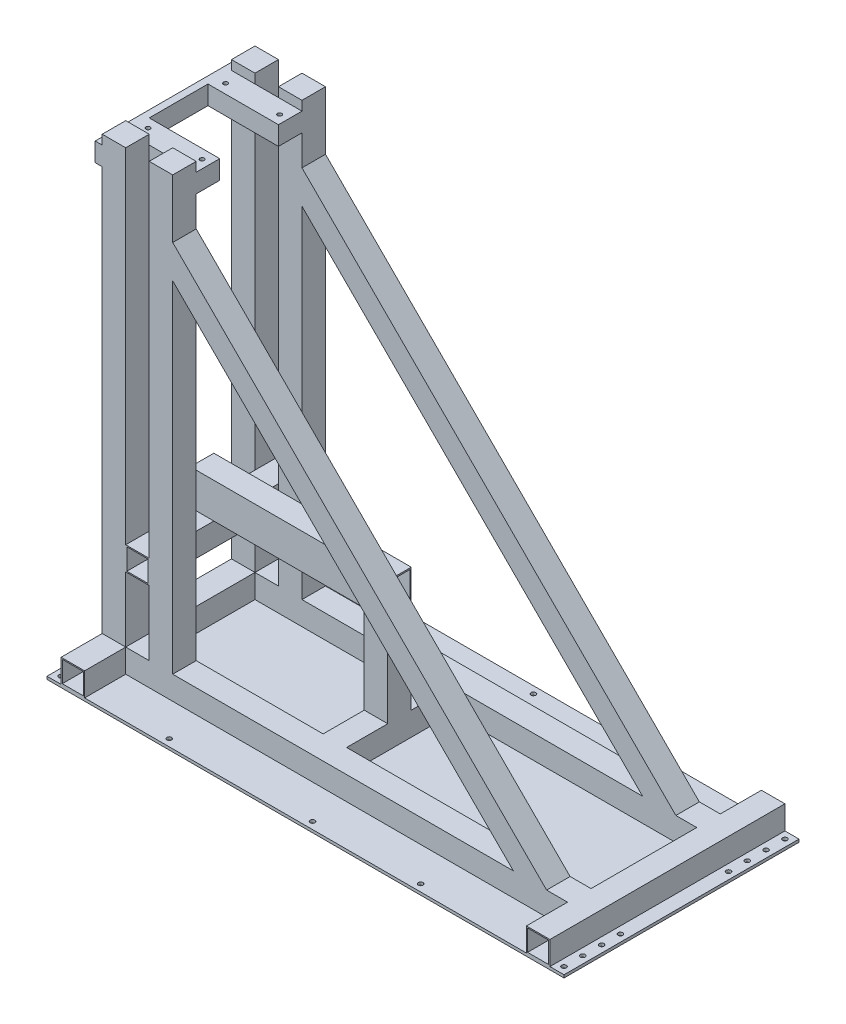
from build123d import *

# Parameters (mm, degrees)
BOSS_EXTRUDE1_DEPTH      = 100
CUT_EXTRUDE3_START       = 5
SKETCH15_W               = 95
SKETCH15_H               = 1837.5
SKETCH15_W_2             = 2080
SKETCH15_H_2             = 95
CUT_EXTRUDE3_DEPTH       = 90
BOSS_EXTRUDE2_DEPTH      = 100
SKETCH2_R                = 9
CUT_EXTRUDE1_DEPTH       = 41
CUT_EXTRUDE1_DEPTH_BACK  = 1901
SKETCH5_W                = 100
SKETCH5_H                = 100
SKETCH5_W_2              = 90
SKETCH5_H_2              = 90
BOSS_EXTRUDE6_DEPTH      = 500
BOSS_EXTRUDE6_DEPTH_BACK = 500
SKETCH6_W                = 650
SKETCH6_H                = 80
BOSS_EXTRUDE7_DEPTH      = 30
SKETCH7_W                = 650
SKETCH7_H                = 100
BOSS_EXTRUDE8_DEPTH      = 100
SKETCH8_W                = 90
SKETCH8_H                = 90
CUT_EXTRUDE2_DEPTH       = 380
SKETCH11_W               = 2200
SKETCH11_H               = 1000
SKETCH11_R               = 10
BOSS_EXTRUDE10_DEPTH     = 12
SKETCH12_W               = 100
SKETCH12_H               = 150
SKETCH12_W_2             = 88
SKETCH12_H_2             = 138
BOSS_EXTRUDE11_DEPTH     = 840
SKETCH18_W               = 100
SKETCH18_H               = 100
SKETCH18_W_2             = 90
SKETCH18_H_2             = 90
BOSS_EXTRUDE13_DEPTH     = 225
SKETCH14_W               = 100
SKETCH14_H               = 100
SKETCH14_W_2             = 90
SKETCH14_H_2             = 90
BOSS_EXTRUDE12_DEPTH     = 377
SKETCH16_W               = 90
SKETCH16_H               = 90
CUT_EXTRUDE4_DEPTH       = 826
SKETCH17_W               = 90
SKETCH17_H               = 90
CUT_EXTRUDE5_DEPTH       = 826


with BuildPart() as part:
    # Base → Boss-Extrude1 (new body)
    with BuildSketch(Plane.XY):
        Polygon((0, 100), (0, 1940), (100, 1940), (100, 1690.99025767), (1690.99025767, 100), (1880, 100), (1880, 0), (100, 0), (0, 0), (-100, 0), (-200, 0), (-200, 1940), (-100, 1940), (-100, 100), align=None)
        Polygon((100, 1549.568901432), (100, 100), (1549.568901432, 100), align=None, mode=Mode.SUBTRACT)
    extrude(amount=BOSS_EXTRUDE1_DEPTH)

    # Sketch15 → Cut-Extrude3 (cut)
    with BuildSketch(Plane.XY.offset(CUT_EXTRUDE3_START)):
        Polygon((100, 1687.454723764), (100, 1556.639969244), (1556.639969244, 100), (1687.454723764, 100), align=None)
        with Locations((-150, 1018.75)):
            Rectangle(SKETCH15_W, SKETCH15_H)
        with Locations((50, 1018.75)):
            Rectangle(SKETCH15_W, SKETCH15_H)
        with Locations((840, 50)):
            Rectangle(SKETCH15_W_2, SKETCH15_H_2)
    extrude(amount=CUT_EXTRUDE3_DEPTH, mode=Mode.SUBTRACT)

    # Sketch1 → Boss-Extrude2 (add)
    with BuildSketch(Plane(origin=(0, 0, 0), x_dir=(-1, 0, 0), z_dir=(0, 0, -1))):
        Polygon((-100, 1900), (10.419601085, 1900), (200, 1900), (200, 1820), (-100, 1820), align=None)
    extrude(amount=BOSS_EXTRUDE2_DEPTH)

    # Sketch2 → Cut-Extrude1 (cut, two sides)
    with BuildSketch(Plane(origin=(0, 1900, 0), x_dir=(1, 0, 0), z_dir=(0, 1, 0))) as cut_extrude1_sk:
        with Locations((-165, 60)):
            Circle(SKETCH2_R)
        with Locations((65, 60)):
            Circle(SKETCH2_R)
    extrude(amount=CUT_EXTRUDE1_DEPTH, mode=Mode.SUBTRACT)
    extrude(cut_extrude1_sk.sketch, amount=-CUT_EXTRUDE1_DEPTH_BACK, mode=Mode.SUBTRACT)


with BuildPart() as body_2:
    # Mirror2: mirrored copy
    add(part.part.mirror(Plane.XY.offset(-225)))


with BuildPart() as part_1:
    add(part.part)

    add(body_2.part)  # Boss-Extrude6 merges body 2
    # Sketch5 → Boss-Extrude6 (add, two sides)
    with BuildSketch(Plane.XY.offset(-225)) as boss_extrude6_sk:
        with Locations((-150, 50)):
            Rectangle(SKETCH5_W, SKETCH5_H)
        with Locations((-150, 50)):
            Rectangle(SKETCH5_W_2, SKETCH5_H_2, mode=Mode.SUBTRACT)
        with Locations((1830, 50)):
            Rectangle(SKETCH5_W, SKETCH5_H)
        with Locations((1830, 50)):
            Rectangle(SKETCH5_W_2, SKETCH5_H_2, mode=Mode.SUBTRACT)
    extrude(amount=BOSS_EXTRUDE6_DEPTH)
    extrude(boss_extrude6_sk.sketch, amount=-BOSS_EXTRUDE6_DEPTH_BACK)

    # Sketch6 → Boss-Extrude7 (add)
    with BuildSketch(Plane.ZY.offset(200)):
        with Locations((-225, 1860)):
            Rectangle(SKETCH6_W, SKETCH6_H)
    extrude(amount=BOSS_EXTRUDE7_DEPTH)

    # Sketch7 → Boss-Extrude8 (add)
    with BuildSketch(Plane.ZY):
        with Locations((-225, 427)):
            Rectangle(SKETCH7_W, SKETCH7_H)
    extrude(amount=BOSS_EXTRUDE8_DEPTH)

    # Sketch8 → Cut-Extrude2 (cut, symmetric)
    with BuildSketch(Plane.XY.offset(-225)):
        with Locations((-50, 427)):
            Rectangle(SKETCH8_W, SKETCH8_H)
    extrude(amount=CUT_EXTRUDE2_DEPTH, both=True, mode=Mode.SUBTRACT)

    # Sketch11 → Boss-Extrude10 (add)
    with BuildSketch(Plane(origin=(0, 0, 0), x_dir=(1, 0, 0), z_dir=(0, 1, 0))):
        with Locations((840, 225)):
            Rectangle(SKETCH11_W, SKETCH11_H)
        with Locations((-230, 695)):
            Circle(SKETCH11_R, mode=Mode.SUBTRACT)
        with Locations((1910, 695)):
            Circle(SKETCH11_R, mode=Mode.SUBTRACT)
        with Locations((1910, 455)):
            Circle(SKETCH11_R, mode=Mode.SUBTRACT)
        with Locations((1910, 535)):
            Circle(SKETCH11_R, mode=Mode.SUBTRACT)
        with Locations((1910, 615)):
            Circle(SKETCH11_R, mode=Mode.SUBTRACT)
        with Locations((1300, 695)):
            Circle(SKETCH11_R, mode=Mode.SUBTRACT)
        with Locations((840, 695)):
            Circle(SKETCH11_R, mode=Mode.SUBTRACT)
        with Locations((230, 695)):
            Circle(SKETCH11_R, mode=Mode.SUBTRACT)
        with Locations((-230, 615)):
            Circle(SKETCH11_R, mode=Mode.SUBTRACT)
        with Locations((-230, 455)):
            Circle(SKETCH11_R, mode=Mode.SUBTRACT)
        with Locations((-230, 535)):
            Circle(SKETCH11_R, mode=Mode.SUBTRACT)
        with Locations((1910, -5)):
            Circle(SKETCH11_R, mode=Mode.SUBTRACT)
        with Locations((1910, -85)):
            Circle(SKETCH11_R, mode=Mode.SUBTRACT)
        with Locations((1910, -165)):
            Circle(SKETCH11_R, mode=Mode.SUBTRACT)
        with Locations((1910, -245)):
            Circle(SKETCH11_R, mode=Mode.SUBTRACT)
        with Locations((1300, -245)):
            Circle(SKETCH11_R, mode=Mode.SUBTRACT)
        with Locations((840, -245)):
            Circle(SKETCH11_R, mode=Mode.SUBTRACT)
        with Locations((230, -245)):
            Circle(SKETCH11_R, mode=Mode.SUBTRACT)
        with Locations((-230, -245)):
            Circle(SKETCH11_R, mode=Mode.SUBTRACT)
        with Locations((-230, -165)):
            Circle(SKETCH11_R, mode=Mode.SUBTRACT)
        with Locations((-230, -85)):
            Circle(SKETCH11_R, mode=Mode.SUBTRACT)
        with Locations((-230, -5)):
            Circle(SKETCH11_R, mode=Mode.SUBTRACT)
    extrude(amount=-BOSS_EXTRUDE10_DEPTH)

    # Sketch12 → Boss-Extrude11 (add)
    with BuildSketch(Plane.ZY.offset(100)):
        with Locations((-225, 552)):
            Rectangle(SKETCH12_W, SKETCH12_H)
        with Locations((-225, 552)):
            Rectangle(SKETCH12_W_2, SKETCH12_H_2, mode=Mode.SUBTRACT)
    extrude(amount=-BOSS_EXTRUDE11_DEPTH)

    # Sketch18 → Boss-Extrude13 (add, symmetric)
    with BuildSketch(Plane.XY.offset(-225)):
        with Locations((690, 50)):
            Rectangle(SKETCH18_W, SKETCH18_H)
        with Locations((690, 50)):
            Rectangle(SKETCH18_W_2, SKETCH18_H_2, mode=Mode.SUBTRACT)
    extrude(amount=BOSS_EXTRUDE13_DEPTH, both=True)

    # Sketch14 → Boss-Extrude12 (add)
    with BuildSketch(Plane.XZ.offset(-477)):
        with Locations((690, -225)):
            Rectangle(SKETCH14_W, SKETCH14_H)
        with Locations((690, -225)):
            Rectangle(SKETCH14_W_2, SKETCH14_H_2, mode=Mode.SUBTRACT)
    extrude(amount=BOSS_EXTRUDE12_DEPTH)

    # Sketch16 → Cut-Extrude4 (cut, through all)
    with BuildSketch(Plane.XY.offset(100)):
        with Locations((-150, 50)):
            Rectangle(SKETCH16_W, SKETCH16_H)
    extrude(amount=-CUT_EXTRUDE4_DEPTH, mode=Mode.SUBTRACT)

    # Sketch17 → Cut-Extrude5 (cut, through all)
    with BuildSketch(Plane.XY.offset(100)):
        with Locations((1830, 50)):
            Rectangle(SKETCH17_W, SKETCH17_H)
    extrude(amount=-CUT_EXTRUDE5_DEPTH, mode=Mode.SUBTRACT)


solid = part_1.part
